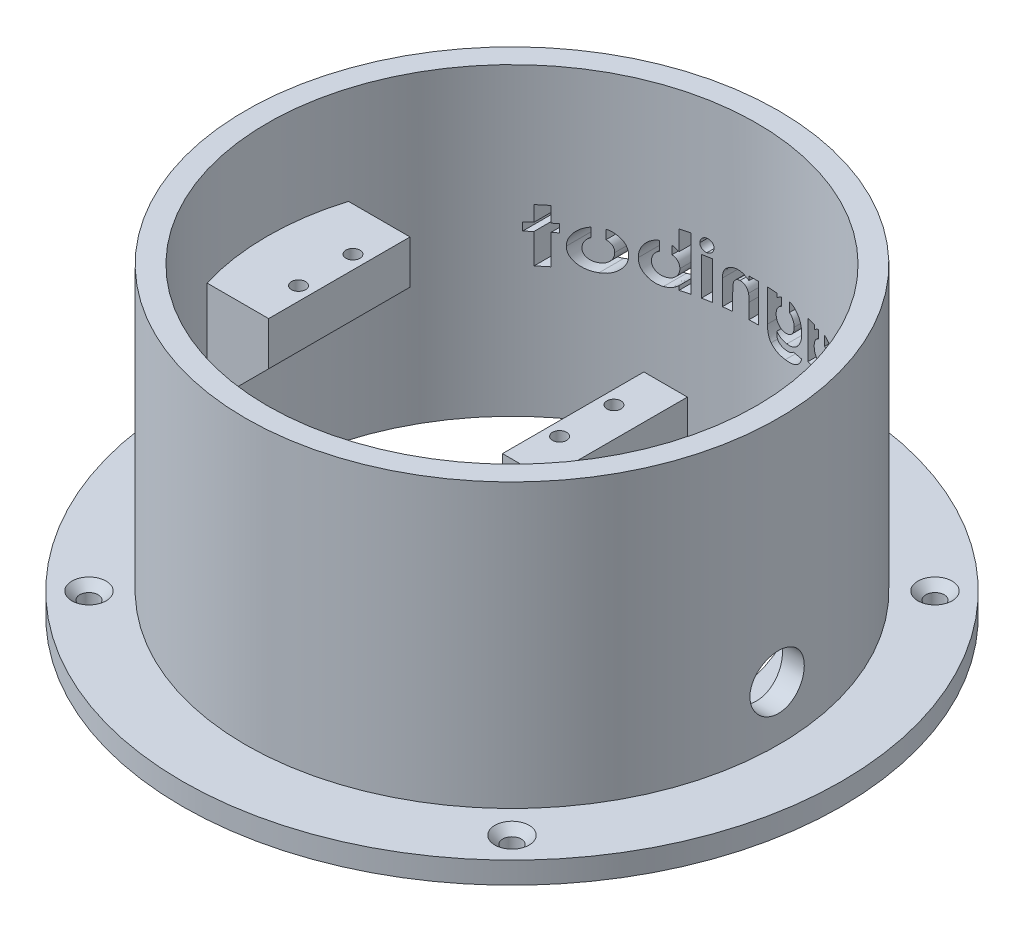
from build123d import *

# Parameters (mm, degrees)
SKETCH1_R                                           = 60.625
SKETCH1_R_2                                         = 45
BOSS_EXTRUDE1_DEPTH                                 = 4
SKETCH2_R                                           = 49
SKETCH2_R_2                                         = 45
BOSS_EXTRUDE2_DEPTH                                 = 52
SKETCH4_W                                           = 13.25
SKETCH4_H                                           = 8
SKETCH4_W_2                                         = 8
SKETCH4_H_2                                         = 38
BOSS_EXTRUDE4_DEPTH                                 = 13
BOSS_EXTRUDE5_DEPTH                                 = 4
SKETCH7_R                                           = 1.3
CUT_EXTRUDE4_DEPTH                                  = 7.2
SKETCH9_W                                           = 10
SKETCH9_H                                           = 24
CUT_EXTRUDE7_DEPTH                                  = 8
CUT_EXTRUDE8_REACH                                  = 111.625
SKETCH11_R                                          = 5
CUT_EXTRUDE9_DEPTH                                  = 5.0000001
CSK_FOR_M3_COUNTERSUNK_FLAT_HEAD_SCREW1_D           = 3.4
CSK_FOR_M3_COUNTERSUNK_FLAT_HEAD_SCREW1_DEPTH       = 4
CSK_FOR_M3_COUNTERSUNK_FLAT_HEAD_SCREW1_CSINK_D     = 6.3
CSK_FOR_M3_COUNTERSUNK_FLAT_HEAD_SCREW1_CSINK_ANGLE = 90
SKETCH18_W                                          = 1.709615384
SKETCH18_H                                          = 6.960576923
CUT_EXTRUDE10_DEPTH                                 = 45


with BuildPart() as part:
    # Sketch1 → Boss-Extrude1 (new body)
    with BuildSketch(Plane(origin=(0, 0, 0), x_dir=(1, 0, 0), z_dir=(0, 1, 0))):
        Circle(SKETCH1_R)
        Circle(SKETCH1_R_2, mode=Mode.SUBTRACT)
    extrude(amount=BOSS_EXTRUDE1_DEPTH)

    # Sketch2 → Boss-Extrude2 (add)
    with BuildSketch(Plane(origin=(0, 4, 0), x_dir=(1, 0, 0), z_dir=(0, 1, 0))):
        Circle(SKETCH2_R)
        Circle(SKETCH2_R_2, mode=Mode.SUBTRACT)
    extrude(amount=BOSS_EXTRUDE2_DEPTH)

    # Sketch4 → Boss-Extrude4 (add, symmetric)
    with BuildSketch(Plane.XY):
        with Locations((-38.375, 34)):
            Rectangle(SKETCH4_W, SKETCH4_H)
        Polygon((-31.75, 30), (-45, 30), (-45, 16.75), align=None)
        with Locations((15.25, 19)):
            Rectangle(SKETCH4_W_2, SKETCH4_H_2)
    extrude(amount=BOSS_EXTRUDE4_DEPTH, both=True)

    # Sketch5 → Boss-Extrude5 (add)
    with BuildSketch(Plane.XZ):
        with BuildLine():
            Line((11.25, 13), (29.067400866, 34.352382842))
            ThreePointArc((29.067400866, 34.352382842), (45, 0), (29.067400866, -34.352382842))
            Line((29.067400866, -34.352382842), (11.25, -13))
            Line((11.25, -13), (11.25, 13))
        make_face()
    extrude(amount=-BOSS_EXTRUDE5_DEPTH)

    # Sketch7 → Cut-Extrude4 (cut)
    with BuildSketch(Plane(origin=(0, 38, 0), x_dir=(1, 0, 0), z_dir=(0, 1, 0))):
        with Locations((-34.25, 5)):
            Circle(SKETCH7_R)
        with Locations((-34.25, -5)):
            Circle(SKETCH7_R)
        with Locations((13.75, 5)):
            Circle(SKETCH7_R)
        with Locations((13.75, -5)):
            Circle(SKETCH7_R)
    extrude(amount=-CUT_EXTRUDE4_DEPTH, mode=Mode.SUBTRACT)

    # Sketch9 → Cut-Extrude7 (cut)
    with BuildSketch(Plane.ZY.offset(-11.25)):
        with Locations((0, 17)):
            Rectangle(SKETCH9_W, SKETCH9_H)
    extrude(amount=-CUT_EXTRUDE7_DEPTH, mode=Mode.SUBTRACT)

    # Sketch11 → Cut-Extrude8 (cut, up to next)
    with BuildSketch(Plane(origin=(49, 0, 0), x_dir=(0, 0, -1), z_dir=(1, 0, 0)), mode=Mode.PRIVATE) as cut_extrude8_sk1:
        with Locations((0, 14)):
            Circle(SKETCH11_R)
    cut_extrude8_tool1 = extrude(cut_extrude8_sk1.sketch, amount=-CUT_EXTRUDE8_REACH, mode=Mode.PRIVATE) & part.part
    add(cut_extrude8_tool1.solids().sort_by_distance((49, 14, 0))[0], mode=Mode.SUBTRACT)

    # Sketch12 → Cut-Extrude9 (cut, through all)
    with BuildSketch(Plane(origin=(0, 4, 0), x_dir=(1, 0, 0), z_dir=(0, 1, 0))):
        with BuildLine():
            Line((29.479537487, 22.359715328), (27.25, 19.687836398))
            Line((27.25, 19.687836398), (27.25, -19.687836398))
            Line((27.25, -19.687836398), (29.479537487, -22.359715328))
            ThreePointArc((29.479537487, -22.359715328), (37, 0), (29.479537487, 22.359715328))
        make_face()
        Polygon((27.25, -19.687836398), (27.25, 19.687836398), (24.25, 16.092634774), (24.25, -16.092634774), align=None)
    extrude(amount=-CUT_EXTRUDE9_DEPTH, mode=Mode.SUBTRACT)

    # CSK for M3 Countersunk Flat Head Screw1
    with Locations(Plane(origin=(0, 4, 0), x_dir=(1, 0, 0), z_dir=(0, 1, 0))):
        with Locations((-38.890872965, 38.890872965), (-38.890872965, -38.890872965), (38.890872965, -38.890872965), (38.890872965, 38.890872965)):
            CounterSinkHole(CSK_FOR_M3_COUNTERSUNK_FLAT_HEAD_SCREW1_D / 2, CSK_FOR_M3_COUNTERSUNK_FLAT_HEAD_SCREW1_CSINK_D / 2, depth=CSK_FOR_M3_COUNTERSUNK_FLAT_HEAD_SCREW1_DEPTH, counter_sink_angle=CSK_FOR_M3_COUNTERSUNK_FLAT_HEAD_SCREW1_CSINK_ANGLE)

    # Sketch18 → Cut-Extrude10 (cut)
    with BuildSketch(Plane(origin=(0, 0, -13), x_dir=(-1, 0, 0), z_dir=(0, 0, -1))):
        with BuildLine():
            add(Edge.make_bspline(
                [(-26.842487981, 29.495192308), (-26.988196434, 29.498038901), (-27.204965825, 29.462307141), (-27.475994694, 29.354907901), (-27.664862129, 29.241566866), (-27.836779719, 29.100355471), (-27.987937046, 28.932127623), (-28.113371328, 28.737009869), (-28.201046352, 28.555679373), (-28.254794589, 28.392139668), (-28.294305339, 28.251942188), (-28.323177251, 28.094008869), (-28.347279044, 27.920113495), (-28.369621116, 27.730048993), (-28.385267336, 27.442939995), (-28.394826017, 27.219060717), (-28.391826923, 27.064332933)],
                knots=[0, 0, 0, 0, 0.13355216, 0.199704678, 0.267120188, 0.335277742, 0.403628311, 0.474205446, 0.54799425, 0.588135642, 0.632411552, 0.681857329, 0.73562936, 0.793897036, 0.857789304, 1, 1, 1, 1], degree=3))
            Line((-28.391826923, 27.064332933), (-28.391826923, 24))
            Line((-28.391826923, 24), (-30.101442308, 24))
            Line((-30.101442308, 24), (-30.101442308, 30.960576923))
            Line((-30.101442308, 30.960576923), (-28.391826923, 30.960576923))
            Line((-28.391826923, 30.960576923), (-28.391826923, 30.128665865))
            add(Edge.make_bspline(
                [(-28.391826923, 30.128665865), (-28.246518571, 30.28386113), (-28.00929586, 30.492748527), (-27.659062917, 30.716852491), (-27.38650362, 30.85144348), (-27.10067853, 30.954023668), (-26.698562474, 31.056158967), (-26.384211282, 31.08134908), (-26.172761418, 31.082692308)],
                knots=[0, 0, 0, 0, 0.256335531, 0.379114138, 0.500550811, 0.622115809, 0.744714581, 1, 1, 1, 1], degree=3))
            add(Edge.make_bspline(
                [(-26.172761418, 31.082692308), (-25.960830072, 31.083493322), (-25.645660174, 31.046822542), (-25.250117073, 30.912238992), (-24.976393607, 30.770998946), (-24.72038138, 30.596258979), (-24.411202082, 30.302229143), (-24.225552609, 30.035457192), (-24.12351262, 29.842457933)],
                knots=[0, 0, 0, 0, 0.251955439, 0.373413672, 0.494801292, 0.617068654, 0.7406196, 1, 1, 1, 1], degree=3))
            add(Edge.make_bspline(
                [(-24.12351262, 29.842457933), (-23.98885255, 30.038239174), (-23.754904191, 30.305456134), (-23.388343741, 30.596264158), (-23.091852347, 30.772294093), (-22.777453929, 30.911749639), (-22.333011237, 31.046004506), (-21.983922354, 31.083556782), (-21.749894832, 31.082692308)],
                knots=[0, 0, 0, 0, 0.25544547, 0.37917652, 0.501904822, 0.625344245, 0.74827832, 1, 1, 1, 1], degree=3))
            add(Edge.make_bspline(
                [(-21.749894832, 31.082692308), (-21.511457683, 31.084814494), (-21.160136901, 31.042896333), (-20.719737815, 30.899120432), (-20.425124803, 30.746464528), (-20.158725744, 30.565394097), (-19.931721755, 30.351514057), (-19.743329163, 30.112219798), (-19.620661389, 29.888780681), (-19.541360075, 29.691234213), (-19.493476883, 29.519331883), (-19.448692906, 29.327381136), (-19.416513393, 29.112802035), (-19.386505118, 28.877610967), (-19.362172784, 28.520569263), (-19.354973526, 28.241721525), (-19.355288462, 28.048888221)],
                knots=[0, 0, 0, 0, 0.16090351, 0.236985873, 0.311729383, 0.384306569, 0.453908175, 0.521546124, 0.589231814, 0.625292706, 0.665128129, 0.709631799, 0.75836798, 0.811604142, 0.869763281, 1, 1, 1, 1], degree=3))
            Line((-19.355288462, 28.048888221), (-19.355288462, 24))
            Line((-19.355288462, 24), (-21.064903846, 24))
            Line((-21.064903846, 24), (-21.064903846, 27.495552885))
            add(Edge.make_bspline(
                [(-21.064903846, 27.495552885), (-21.068140687, 27.674833554), (-21.070356959, 27.932935713), (-21.106654363, 28.25937097), (-21.137126743, 28.470145996), (-21.18072093, 28.657138802), (-21.233878599, 28.820796093), (-21.295540637, 28.961354328), (-21.369995815, 29.078798806), (-21.453385673, 29.177705228), (-21.546144876, 29.262489002), (-21.647306212, 29.334821229), (-21.757787048, 29.396493405), (-21.880480962, 29.438131039), (-22.059414371, 29.483235592), (-22.200832369, 29.497359509), (-22.29750601, 29.495192308)],
                knots=[0, 0, 0, 0, 0.200235118, 0.287286636, 0.36626042, 0.437682721, 0.501179832, 0.55802122, 0.608412149, 0.655743055, 0.701943669, 0.748215056, 0.794251934, 0.84250453, 0.892236791, 1, 1, 1, 1], degree=3))
            add(Edge.make_bspline(
                [(-22.29750601, 29.495192308), (-22.447521501, 29.496164897), (-22.671943821, 29.466348726), (-22.949430786, 29.356428903), (-23.141804083, 29.246128469), (-23.316353958, 29.108174057), (-23.469039265, 28.944596141), (-23.595136439, 28.754397482), (-23.682423957, 28.577934251), (-23.736967516, 28.418375354), (-23.775443704, 28.281726094), (-23.805431502, 28.127195878), (-23.828915596, 27.95635021), (-23.851390901, 27.768221413), (-23.866979995, 27.483641738), (-23.8765728, 27.261678322), (-23.873557692, 27.108218149)],
                knots=[0, 0, 0, 0, 0.138576891, 0.20607346, 0.274463188, 0.342600369, 0.410740079, 0.480118385, 0.552600476, 0.591784346, 0.635663039, 0.683568788, 0.736964635, 0.79487093, 0.858420857, 1, 1, 1, 1], degree=3))
            Line((-23.873557692, 27.108218149), (-23.873557692, 24))
            Line((-23.873557692, 24), (-25.583173077, 24))
            Line((-25.583173077, 24), (-25.583173077, 27.337184495))
            add(Edge.make_bspline(
                [(-25.583173077, 27.337184495), (-25.581929367, 27.480364046), (-25.587494863, 27.687209995), (-25.602902154, 27.952402752), (-25.6182858, 28.127983872), (-25.636060725, 28.288035163), (-25.661704733, 28.431681339), (-25.68864776, 28.559713845), (-25.734841386, 28.70515501), (-25.799934185, 28.866327836), (-25.897184162, 29.037243969), (-26.014771218, 29.180341574), (-26.149729591, 29.29675473), (-26.302220032, 29.385397216), (-26.529198096, 29.475712011), (-26.717247278, 29.492268234), (-26.842487981, 29.495192308)],
                knots=[0, 0, 0, 0, 0.151067163, 0.218305464, 0.280286667, 0.337063553, 0.388152346, 0.434234333, 0.474994116, 0.549030637, 0.617296196, 0.681662637, 0.743542005, 0.804319575, 0.867012585, 1, 1, 1, 1], degree=3))
        make_face()
        with BuildLine():
            Line((-10.685096154, 30.960576923), (-12.394711538, 30.960576923))
            Line((-12.394711538, 30.960576923), (-12.394711538, 30.176367188))
            add(Edge.make_bspline(
                [(-13.394766241, 30.846325903), (-13.310273388, 30.811242607), (-13.135129326, 30.729510449), (-12.789159208, 30.520493059), (-12.5451071, 30.323924112), (-12.394711538, 30.176367188)],
                knots=[0.505665216, 0.505665216, 0.505665216, 0.505665216, 0.617680221, 0.742091207, 1, 1, 1, 1], degree=3))
            Line((-13.394766241, 30.846325903), (-13.394766241, 29.329440504))
            add(Edge.make_bspline(
                [(-12.272596154, 27.49936899), (-12.275060695, 27.640851441), (-12.286903949, 27.850610329), (-12.347552937, 28.118783015), (-12.407830208, 28.305751844), (-12.486754381, 28.48203362), (-12.585417382, 28.645666236), (-12.69736389, 28.802320919), (-12.829721006, 28.943228332), (-12.971811749, 29.07413986), (-13.126905871, 29.186060901), (-13.268832014, 29.269936251), (-13.359799297, 29.313990727), (-13.394766241, 29.329440504)],
                knots=[0, 0, 0, 0, 0.135095843, 0.199062931, 0.26154836, 0.322044302, 0.382646423, 0.443384787, 0.505154721, 0.566515904, 0.627254268, 0.687026267, 0.723436876, 0.723436876, 0.723436876, 0.723436876], degree=3))
            add(Edge.make_bspline(
                [(-14.235982572, 25.465384615), (-14.10011477, 25.467643209), (-13.898799708, 25.480332454), (-13.640806303, 25.53963291), (-13.460804722, 25.604109848), (-13.288221764, 25.681696153), (-13.124620215, 25.777647683), (-12.971773985, 25.89305892), (-12.828909303, 26.024925234), (-12.698001522, 26.169745041), (-12.58481344, 26.328550432), (-12.486224946, 26.496261974), (-12.408680476, 26.676846784), (-12.347134367, 26.867138563), (-12.286934546, 27.140607111), (-12.275196888, 27.354702397), (-12.272596154, 27.49936899)],
                knots=[0, 0, 0, 0, 0.128661741, 0.189789734, 0.249707447, 0.309188905, 0.368499841, 0.428643518, 0.489936978, 0.552121002, 0.612878024, 0.674050383, 0.735729182, 0.798304624, 0.862952782, 1, 1, 1, 1], degree=3))
            add(Edge.make_bspline(
                [(-16.180288462, 27.493644832), (-16.177753543, 27.352107797), (-16.165553709, 27.142550903), (-16.105972787, 26.873813056), (-16.042025644, 26.686589642), (-15.963884487, 26.507939562), (-15.868781379, 26.338693239), (-15.75196058, 26.181841637), (-15.622339039, 26.033673393), (-15.477365155, 25.901365306), (-15.324904215, 25.783886331), (-15.162873633, 25.685597292), (-14.993031423, 25.606139103), (-14.815948987, 25.541463433), (-14.564127631, 25.483260542), (-14.368366115, 25.465966115), (-14.235982572, 25.465384615)],
                knots=[0, 0, 0, 0, 0.135364742, 0.199460916, 0.262263612, 0.323991109, 0.385461119, 0.447170687, 0.510418175, 0.573170928, 0.634270788, 0.693953647, 0.753722967, 0.813083582, 0.873628543, 1, 1, 1, 1], degree=3))
            add(Edge.make_bspline(
                [(-15.104766241, 29.310891047), (-15.128357367, 29.299714144), (-15.207610898, 29.260034442), (-15.337370386, 29.180793558), (-15.488973559, 29.065116813), (-15.631033087, 28.934431912), (-15.760541149, 28.790785074), (-15.872185186, 28.634035169), (-15.967062601, 28.468406347), (-16.047311646, 28.293397945), (-16.10472424, 28.106949337), (-16.166516957, 27.841905768), (-16.177251536, 27.633746436), (-16.180288462, 27.493644832)],
                knots=[0.284645674, 0.284645674, 0.284645674, 0.284645674, 0.30974405, 0.369855539, 0.430536995, 0.492876096, 0.555257199, 0.616197084, 0.67757746, 0.738630831, 0.800921896, 0.864881541, 1, 1, 1, 1], degree=3))
            Line((-15.104766241, 29.310891047), (-15.104766241, 31.04733117))
            add(Edge.make_bspline(
                [(-17.889903846, 27.466932091), (-17.887893117, 27.720081558), (-17.86504439, 28.095154051), (-17.760403741, 28.575169229), (-17.655770658, 28.910764723), (-17.521064587, 29.22848271), (-17.357029895, 29.5288338), (-17.161404408, 29.811035446), (-16.935982638, 30.070283963), (-16.692582034, 30.307896996), (-16.432186421, 30.514760791), (-16.158868224, 30.690491148), (-15.872334992, 30.833991927), (-15.57263517, 30.944747788), (-15.315122826, 31.012054464), (-15.157587593, 31.039528345), (-15.104766241, 31.04733117)],
                knots=[0, 0, 0, 0, 0.139308968, 0.205473642, 0.26959838, 0.332253223, 0.394830003, 0.45737553, 0.520581844, 0.583374035, 0.644082429, 0.703039519, 0.761664045, 0.819843943, 0.878346403, 0.907680046, 0.907680046, 0.907680046, 0.907680046], degree=3))
            add(Edge.make_bspline(
                [(-14.550811298, 23.877884615), (-14.771194945, 23.875519618), (-15.097918989, 23.909256248), (-15.518197746, 24.017521116), (-15.819029415, 24.13040656), (-16.107936569, 24.27691408), (-16.387131536, 24.452984729), (-16.651827659, 24.664864734), (-16.904228747, 24.903368832), (-17.135325055, 25.165726181), (-17.337353842, 25.448294059), (-17.507641007, 25.747064711), (-17.647178129, 26.061049428), (-17.756829985, 26.390010448), (-17.863179509, 26.856878675), (-17.889066519, 27.221178873), (-17.889903846, 27.466932091)],
                knots=[0, 0, 0, 0, 0.121092325, 0.179634237, 0.238303512, 0.297437091, 0.357506849, 0.419513154, 0.483600041, 0.548295031, 0.611486872, 0.674312645, 0.737107248, 0.800159515, 0.864737133, 1, 1, 1, 1], degree=3))
            add(Edge.make_bspline(
                [(-12.394711538, 24.759405048), (-12.556438107, 24.613336017), (-12.80579393, 24.412909112), (-13.162727189, 24.202367243), (-13.424496711, 24.08000868), (-13.692348157, 23.989796988), (-14.064934751, 23.90107922), (-14.355434994, 23.879194523), (-14.550811298, 23.877884615)],
                knots=[0, 0, 0, 0, 0.273943506, 0.399987178, 0.519718967, 0.636176176, 0.754371141, 1, 1, 1, 1], degree=3))
            Line((-12.394711538, 24.759405048), (-12.394711538, 24))
            Line((-12.394711538, 24), (-10.685096154, 24))
            Line((-10.685096154, 24), (-10.685096154, 30.960576923))
        make_face()
        with BuildLine():
            Line((-2.014903846, 30.960576923), (-3.846634615, 30.960576923))
            Line((-3.846634615, 30.960576923), (-3.846634615, 30.185907452))
            add(Edge.make_bspline(
                [(-4.767307692, 30.814230123), (-4.724477087, 30.794772406), (-4.590493141, 30.729827243), (-4.269492644, 30.538805478), (-4.012351526, 30.336800768), (-3.846634615, 30.185907452)],
                knots=[0.536763775, 0.536763775, 0.536763775, 0.536763775, 0.595177246, 0.721609329, 1, 1, 1, 1], degree=3))
            Line((-4.767307692, 30.814230123), (-4.767307692, 29.320900687))
            add(Edge.make_bspline(
                [(-3.724519231, 27.547070313), (-3.723985612, 27.684921804), (-3.738077468, 27.888553288), (-3.795878184, 28.149010676), (-3.852746707, 28.331467089), (-3.92694536, 28.503911256), (-4.019968331, 28.66473411), (-4.126349389, 28.81690634), (-4.251607924, 28.955244463), (-4.386618444, 29.083193729), (-4.535464026, 29.191438066), (-4.662702685, 29.26982308), (-4.741830963, 29.309083747), (-4.767307692, 29.320900687)],
                knots=[0, 0, 0, 0, 0.135592213, 0.199608616, 0.261894986, 0.32322003, 0.383707537, 0.444249949, 0.505361089, 0.566851635, 0.626748183, 0.685935715, 0.713527333, 0.713527333, 0.713527333, 0.713527333], degree=3))
            add(Edge.make_bspline(
                [(-5.584870793, 25.5875), (-5.454885958, 25.585020274), (-5.263798901, 25.604031441), (-5.018163858, 25.660529884), (-4.845887876, 25.719523311), (-4.683344123, 25.796656464), (-4.528349074, 25.888670415), (-4.38419113, 26.000026641), (-4.248136037, 26.125920215), (-4.125355319, 26.26591114), (-4.016979898, 26.417589382), (-3.927957635, 26.580982169), (-3.852112777, 26.753503944), (-3.796017699, 26.93758312), (-3.737790866, 27.201095495), (-3.724286438, 27.407370932), (-3.724519231, 27.547070313)],
                knots=[0, 0, 0, 0, 0.128347402, 0.189067593, 0.248938142, 0.308023861, 0.366703119, 0.426834097, 0.487804601, 0.549753476, 0.610659063, 0.671749482, 0.733442395, 0.796702453, 0.861717283, 1, 1, 1, 1], degree=3))
            add(Edge.make_bspline(
                [(-7.510096154, 27.560426683), (-7.512631606, 27.421551138), (-7.493433253, 27.218005211), (-7.437602911, 26.955335594), (-7.376070293, 26.772902995), (-7.298907685, 26.599118093), (-7.206250188, 26.434062959), (-7.09186074, 26.281684873), (-6.964837373, 26.138630134), (-6.824314641, 26.009292499), (-6.67305439, 25.896795809), (-6.514171146, 25.799646023), (-6.344228396, 25.723890246), (-6.166910774, 25.66253924), (-5.914630439, 25.602081397), (-5.71748417, 25.59010512), (-5.584870793, 25.5875)],
                knots=[0, 0, 0, 0, 0.134674643, 0.197931502, 0.260447922, 0.321293636, 0.382442821, 0.443853595, 0.505984202, 0.568071793, 0.628986467, 0.688848821, 0.748567548, 0.80932852, 0.870916168, 1, 1, 1, 1], degree=3))
            add(Edge.make_bspline(
                [(-6.477307692, 29.308506905), (-6.496110819, 29.299218872), (-6.569021818, 29.261444461), (-6.691391764, 29.186398323), (-6.840503272, 29.074852735), (-6.977284603, 28.945757425), (-7.10407087, 28.806266755), (-7.210527495, 28.652749523), (-7.305390111, 28.493946497), (-7.379193317, 28.323470163), (-7.440093553, 28.14593706), (-7.491184894, 27.890883778), (-7.513785795, 27.694490093), (-7.510096154, 27.560426683)],
                knots=[0.292846116, 0.292846116, 0.292846116, 0.292846116, 0.313596585, 0.374077456, 0.434784119, 0.497609537, 0.5600519, 0.621032311, 0.682272297, 0.742887436, 0.804620819, 0.867735932, 1, 1, 1, 1], degree=3))
            Line((-6.477307692, 29.308506905), (-6.477307692, 31.053484371))
            add(Edge.make_bspline(
                [(-8.210351562, 30.182091346), (-8.062892974, 30.32841237), (-7.824605249, 30.524618663), (-7.477383775, 30.735792746), (-7.208361065, 30.861886627), (-6.928782705, 30.96208958), (-6.683039299, 31.021567874), (-6.531127889, 31.046194335), (-6.477307692, 31.053484371)],
                knots=[0, 0, 0, 0, 0.256681043, 0.3797841, 0.501470579, 0.623319496, 0.746312038, 0.8134232, 0.8134232, 0.8134232, 0.8134232], degree=3))
            add(Edge.make_bspline(
                [(-9.219711538, 27.541346154), (-9.221119919, 27.802624039), (-9.190880522, 28.187260302), (-9.085236081, 28.680667949), (-8.975256648, 29.02328411), (-8.830419755, 29.344336616), (-8.597264234, 29.747009659), (-8.376926533, 30.019294713), (-8.210351562, 30.182091346)],
                knots=[0, 0, 0, 0, 0.269734209, 0.396745187, 0.520318914, 0.64054729, 0.759723539, 1, 1, 1, 1], degree=3))
            add(Edge.make_bspline(
                [(-5.930228365, 24), (-6.152932763, 23.998495138), (-6.483421931, 24.029911389), (-6.90743633, 24.135684656), (-7.208893191, 24.243870114), (-7.494840772, 24.387709988), (-7.769346837, 24.558788475), (-8.027324309, 24.766145612), (-8.272332389, 24.998190748), (-8.493775749, 25.256120065), (-8.688634356, 25.533135598), (-8.852897135, 25.827326537), (-8.986509958, 26.13842036), (-9.092853484, 26.465107174), (-9.192743563, 26.93200642), (-9.218830866, 27.295560831), (-9.219711538, 27.541346154)],
                knots=[0, 0, 0, 0, 0.123700343, 0.183445285, 0.242476179, 0.301272795, 0.36098846, 0.421869333, 0.484863659, 0.548268086, 0.61043108, 0.672769643, 0.735140257, 0.798288065, 0.863379995, 1, 1, 1, 1], degree=3))
            add(Edge.make_bspline(
                [(-3.846634615, 24.868164063), (-3.98909843, 24.721521045), (-4.215491951, 24.523655782), (-4.547876247, 24.317476268), (-4.797702087, 24.197316109), (-5.059589779, 24.109448793), (-5.435024982, 24.022930448), (-5.72974928, 24.001013175), (-5.930228365, 24)],
                knots=[0, 0, 0, 0, 0.263927751, 0.385523834, 0.50370538, 0.620733321, 0.741155395, 1, 1, 1, 1], degree=3))
            add(Edge.make_bspline(
                [(-5.735606971, 22.900961538), (-5.525196523, 22.899276388), (-5.22448664, 22.923597434), (-4.851215663, 23.01425836), (-4.620987063, 23.11085449), (-4.422356529, 23.226997653), (-4.256650546, 23.361885863), (-4.119825558, 23.510466811), (-4.030327646, 23.650243846), (-3.977144805, 23.77704456), (-3.940929942, 23.886535102), (-3.913430242, 24.012742877), (-3.888388037, 24.153305504), (-3.869711495, 24.310034838), (-3.852264706, 24.549844117), (-3.844166728, 24.73762836), (-3.846634615, 24.868164063)],
                knots=[0, 0, 0, 0, 0.19772075, 0.282265633, 0.359994231, 0.431569103, 0.497870001, 0.560090238, 0.620807047, 0.652681998, 0.689174246, 0.729059971, 0.773983044, 0.823375087, 0.877349713, 1, 1, 1, 1], degree=3))
            add(Edge.make_bspline(
                [(-7.326923077, 23.511538462), (-7.242380589, 23.410960965), (-7.09438231, 23.276179867), (-6.865258268, 23.136766102), (-6.674394322, 23.050135373), (-6.464624278, 22.984387324), (-6.152217667, 22.915381349), (-5.904480947, 22.901982511), (-5.735606971, 22.900961538)],
                knots=[0, 0, 0, 0, 0.22365493, 0.337943226, 0.455777244, 0.579824406, 0.711809474, 1, 1, 1, 1], degree=3))
            Line((-7.326923077, 23.511538462), (-9.22734375, 23.511538462))
            add(Edge.make_bspline(
                [(-5.607767428, 21.313461538), (-5.923289422, 21.313265407), (-6.380155639, 21.337583659), (-6.955064069, 21.447487367), (-7.329970807, 21.55820764), (-7.669881143, 21.701190442), (-7.981201857, 21.872605913), (-8.263321238, 22.077558287), (-8.520560809, 22.307942318), (-8.746742268, 22.568885243), (-9.008284666, 22.958824451), (-9.152772399, 23.284583153), (-9.22734375, 23.511538462)],
                knots=[0, 0, 0, 0, 0.207410699, 0.299345031, 0.383942479, 0.463709986, 0.54113669, 0.616854835, 0.692286579, 0.767513249, 0.843065229, 1, 1, 1, 1], degree=3))
            add(Edge.make_bspline(
                [(-2.726607572, 22.435396635), (-2.883402534, 22.249158648), (-3.157412194, 22.001321583), (-3.579225271, 21.744105205), (-3.926838228, 21.584854194), (-4.305110793, 21.463833728), (-4.864867171, 21.343405218), (-5.305869432, 21.312752008), (-5.607767428, 21.313461538)],
                knots=[0, 0, 0, 0, 0.228421157, 0.343996608, 0.46295648, 0.586702957, 0.716302913, 1, 1, 1, 1], degree=3))
            add(Edge.make_bspline(
                [(-2.014903846, 25.022716346), (-2.01605019, 24.748857441), (-2.032888638, 24.350205066), (-2.10790658, 23.841573981), (-2.185622487, 23.501846955), (-2.286280671, 23.191966583), (-2.445487195, 22.825495506), (-2.603406818, 22.579293056), (-2.726607572, 22.435396635)],
                knots=[0, 0, 0, 0, 0.300233823, 0.436256712, 0.562884572, 0.681680621, 0.792783658, 1, 1, 1, 1], degree=3))
            Line((-2.014903846, 25.022716346), (-2.014903846, 30.960576923))
        make_face()
        with BuildLine():
            add(Edge.make_bspline(
                [(1.484465144, 28.171003606), (1.466486465, 28.102133912), (1.453307231, 27.985137756), (1.43216254, 27.814589763), (1.425478116, 27.651348174), (1.414090003, 27.46451461), (1.408057747, 27.168010661), (1.404442551, 26.933984684), (1.404326923, 26.770492788)],
                knots=[0, 0, 0, 0, 0.151475868, 0.251213212, 0.366854146, 0.500124386, 0.650932297, 1, 1, 1, 1], degree=3))
            Line((1.404326923, 26.770492788), (1.404326923, 24))
            Line((1.404326923, 24), (-0.305288462, 24))
            Line((-0.305288462, 24), (-0.305288462, 30.960576923))
            Line((-0.305288462, 30.960576923), (1.404326923, 30.960576923))
            Line((1.404326923, 30.960576923), (1.404326923, 30.22406851))
            add(Edge.make_bspline(
                [(1.404326923, 30.22406851), (1.588082988, 30.372253646), (1.863824612, 30.569162852), (2.239123782, 30.781038124), (2.496605832, 30.89620558), (2.749040746, 30.978882544), (3.08353522, 31.058574307), (3.339932733, 31.083729401), (3.510817308, 31.082692308)],
                knots=[0, 0, 0, 0, 0.30498931, 0.436681429, 0.556242249, 0.668759084, 0.77937854, 1, 1, 1, 1], degree=3))
            add(Edge.make_bspline(
                [(3.510817308, 31.082692308), (3.680448828, 31.08075736), (3.933391103, 31.064483298), (4.256758659, 30.985147067), (4.487401972, 30.907574271), (4.707179343, 30.805055755), (4.99224116, 30.641514609), (5.182040003, 30.47978274), (5.302478966, 30.365264423)],
                knots=[0, 0, 0, 0, 0.257369373, 0.381171348, 0.503298819, 0.625247689, 0.747811067, 1, 1, 1, 1], degree=3))
            add(Edge.make_bspline(
                [(5.302478966, 30.365264423), (5.405932581, 30.262683941), (5.5432377, 30.088552258), (5.685323238, 29.826244326), (5.773727429, 29.609531908), (5.83891886, 29.372851877), (5.908035146, 29.024814881), (5.921535144, 28.750707555), (5.922596154, 28.5640625)],
                knots=[0, 0, 0, 0, 0.223210024, 0.337545587, 0.456528166, 0.581243817, 0.713405156, 1, 1, 1, 1], degree=3))
            Line((5.922596154, 28.5640625), (5.922596154, 24))
            Line((5.922596154, 24), (4.212980769, 24))
            Line((4.212980769, 24), (4.212980769, 27.022355769))
            add(Edge.make_bspline(
                [(4.212980769, 27.022355769), (4.212493766, 27.211243199), (4.210812206, 27.481734912), (4.1962179, 27.824407045), (4.18675366, 28.042839559), (4.168165199, 28.234750825), (4.151402553, 28.401355154), (4.125681655, 28.541141203), (4.092214633, 28.691502171), (4.033772991, 28.852490497), (3.943045042, 29.022120722), (3.827944434, 29.166217201), (3.693170097, 29.285829147), (3.538879239, 29.38034416), (3.303028662, 29.472102945), (3.109660441, 29.495738343), (2.978470553, 29.495192308)],
                knots=[0, 0, 0, 0, 0.179518406, 0.256936513, 0.325929829, 0.387212867, 0.440139084, 0.484952067, 0.522188202, 0.586422033, 0.647003712, 0.704201966, 0.760716033, 0.817414001, 0.87521257, 1, 1, 1, 1], degree=3))
            add(Edge.make_bspline(
                [(2.978470553, 29.495192308), (2.805477806, 29.493406973), (2.544941693, 29.455299423), (2.233950501, 29.302362646), (2.025539256, 29.146180395), (1.84161366, 28.953101705), (1.632730493, 28.637036758), (1.530975425, 28.363566523), (1.484465144, 28.171003606)],
                knots=[0, 0, 0, 0, 0.240657962, 0.35738999, 0.477137096, 0.600008858, 0.725224946, 1, 1, 1, 1], degree=3))
        make_face()
        with Locations((8.364903846, 27.480288462)):
            Rectangle(SKETCH18_W, SKETCH18_H)
        with BuildLine():
            add(Edge.make_bspline(
                [(7.265865385, 32.750330529), (7.26826571, 32.898800121), (7.301809284, 33.123992504), (7.442819571, 33.387441681), (7.581566689, 33.56215972), (7.748301082, 33.708202376), (8.002527482, 33.849907978), (8.217416018, 33.892511937), (8.36108774, 33.891346154)],
                knots=[0, 0, 0, 0, 0.255026588, 0.378937478, 0.506522648, 0.634371171, 0.754975888, 1, 1, 1, 1], degree=3))
            add(Edge.make_bspline(
                [(8.36108774, 33.891346154), (8.50572535, 33.893726285), (8.722578746, 33.848887063), (8.976980236, 33.702667204), (9.145189704, 33.553861868), (9.284954848, 33.37588626), (9.429451762, 33.107458896), (9.461110928, 32.876834089), (9.463942308, 32.725525841)],
                knots=[0, 0, 0, 0, 0.242962799, 0.363854564, 0.490606197, 0.618739544, 0.743300131, 1, 1, 1, 1], degree=3))
            add(Edge.make_bspline(
                [(9.463942308, 32.725525841), (9.462823205, 32.575352936), (9.426744781, 32.34888392), (9.287851515, 32.08058497), (9.146978933, 31.905250348), (8.980599716, 31.758807889), (8.731970407, 31.610310399), (8.516181568, 31.571234077), (8.374444111, 31.571153846)],
                knots=[0, 0, 0, 0, 0.256468948, 0.381954886, 0.51070434, 0.637377053, 0.757775202, 1, 1, 1, 1], degree=3))
            add(Edge.make_bspline(
                [(8.374444111, 31.571153846), (8.228392073, 31.568584808), (8.010279618, 31.613961149), (7.752417461, 31.759104087), (7.584921087, 31.910946082), (7.44360454, 32.090205686), (7.304907407, 32.365264446), (7.265535894, 32.595858978), (7.265865385, 32.750330529)],
                knots=[0, 0, 0, 0, 0.242758603, 0.363442651, 0.489711254, 0.617482185, 0.742279995, 1, 1, 1, 1], degree=3))
        make_face()
        with BuildLine():
            Line((12.516826923, 30.149654447), (12.516826923, 33.769230769))
            Line((12.516826923, 33.769230769), (10.807211538, 33.769230769))
            Line((10.807211538, 33.769230769), (10.807211538, 24))
            Line((10.807211538, 24), (12.516826923, 24))
            Line((12.516826923, 24), (12.516826923, 24.759405048))
            add(Edge.make_bspline(
                [(14.676742788, 23.877884615), (14.481340525, 23.879044105), (14.190295273, 23.90141522), (13.816420162, 23.989838815), (13.547100901, 24.079591834), (13.284859025, 24.202413115), (12.927897083, 24.412875007), (12.678560162, 24.613354615), (12.516826923, 24.759405048)],
                knots=[0, 0, 0, 0, 0.245252626, 0.364042958, 0.481077093, 0.600625487, 0.726476096, 1, 1, 1, 1], degree=3))
            add(Edge.make_bspline(
                [(18.012019231, 27.466932091), (18.011181865, 27.221178923), (17.985294968, 26.856878579), (17.878945263, 26.390010584), (17.7692939, 26.061048931), (17.629754954, 25.747066559), (17.459474608, 25.448287137), (17.257420023, 25.165752444), (17.026422023, 24.903268641), (16.774022458, 24.665571143), (16.511040433, 24.452305205), (16.232237726, 24.277564662), (15.944584836, 24.129931236), (15.643546412, 24.017226421), (15.22306157, 23.909995441), (14.896589543, 23.874990677), (14.676742788, 23.877884615)],
                knots=[0, 0, 0, 0, 0.135343154, 0.199959102, 0.263048795, 0.32588067, 0.388743734, 0.451973083, 0.516706474, 0.580831401, 0.642600426, 0.702705839, 0.761562083, 0.820266181, 0.879181718, 1, 1, 1, 1], degree=3))
            add(Edge.make_bspline(
                [(15.218097957, 31.048901427), (15.274501403, 31.040721291), (15.436248135, 31.01276704), (15.697481837, 30.94541187), (15.996490365, 30.834072506), (16.281554263, 30.6893286), (16.555871945, 30.516072705), (16.814713657, 30.307102437), (17.058205037, 30.070412022), (17.283440222, 29.810980855), (17.479354913, 29.528924179), (17.642538467, 29.22795498), (17.780866368, 28.91162813), (17.881742065, 28.574710049), (17.987743146, 28.095349683), (18.009700374, 27.719978228), (18.012019231, 27.466932091)],
                knots=[0.090050164, 0.090050164, 0.090050164, 0.090050164, 0.121379711, 0.180255513, 0.238142193, 0.296488846, 0.355775695, 0.416246569, 0.479075999, 0.542319797, 0.604902417, 0.667516308, 0.730345738, 0.794404503, 0.860608415, 1, 1, 1, 1], degree=3))
            Line((15.218097957, 31.048901427), (15.218097957, 29.314704791))
            add(Edge.make_bspline(
                [(16.302403846, 27.493644832), (16.299366921, 27.633746438), (16.28863234, 27.841905764), (16.226839627, 28.106949342), (16.169427021, 28.293397925), (16.089178022, 28.468406422), (15.994300434, 28.634034891), (15.882657044, 28.790786113), (15.753146514, 28.934427931), (15.611096154, 29.06513148), (15.459459761, 29.180740652), (15.327073536, 29.261851626), (15.244691035, 29.302412618), (15.218097957, 29.314704791)],
                knots=[0, 0, 0, 0, 0.134801712, 0.198611423, 0.260756464, 0.321666712, 0.3829032, 0.443700229, 0.505935097, 0.568128061, 0.628667267, 0.688637842, 0.716736573, 0.716736573, 0.716736573, 0.716736573], degree=3))
            add(Edge.make_bspline(
                [(14.358097957, 25.465384615), (14.490373882, 25.46633226), (14.68583074, 25.482503424), (14.937152433, 25.542290355), (15.11434859, 25.60505308), (15.283662909, 25.686858719), (15.44663417, 25.782563199), (15.597636669, 25.902145009), (15.742594365, 26.0335741), (15.872292584, 26.181788724), (15.988648215, 26.339247216), (16.086387681, 26.507354655), (16.16400061, 26.686669989), (16.228126701, 26.87379101), (16.287641674, 27.142566592), (16.299883332, 27.352099555), (16.302403846, 27.493644832)],
                knots=[0, 0, 0, 0, 0.126400154, 0.186367942, 0.246314189, 0.305548276, 0.365764773, 0.426396562, 0.489163565, 0.552425415, 0.614148995, 0.67593532, 0.737676833, 0.80049379, 0.86460452, 1, 1, 1, 1], degree=3))
            add(Edge.make_bspline(
                [(12.394711538, 27.49936899), (12.39733176, 27.354714463), (12.409013133, 27.140584327), (12.469300974, 26.867170278), (12.530611485, 26.676732625), (12.60888957, 26.496971088), (12.704293464, 26.327226497), (12.820695379, 26.17121855), (12.94886675, 26.023478036), (13.093980787, 25.893815066), (13.246613817, 25.77752438), (13.410369681, 25.681729092), (13.582911317, 25.604100949), (13.762924089, 25.539635342), (14.020913389, 25.480330729), (14.222231055, 25.467644121), (14.358097957, 25.465384615)],
                knots=[0, 0, 0, 0, 0.137033778, 0.201675597, 0.264244903, 0.325917654, 0.386784692, 0.447888937, 0.509667152, 0.571398516, 0.631536295, 0.690841415, 0.75031704, 0.810228878, 0.871350876, 1, 1, 1, 1], degree=3))
            add(Edge.make_bspline(
                [(13.508097957, 29.326291338), (13.475510944, 29.311704232), (13.386886451, 29.268645059), (13.247188716, 29.186777003), (13.09386491, 29.07271497), (12.949642647, 28.94476397), (12.820047629, 28.800818686), (12.704913012, 28.647005617), (12.609396037, 28.481322315), (12.529762718, 28.305867591), (12.469718998, 28.118750941), (12.40898317, 27.850633218), (12.397195335, 27.640839254), (12.394711538, 27.49936899)],
                knots=[0.277795958, 0.277795958, 0.277795958, 0.277795958, 0.311877721, 0.371779544, 0.432159902, 0.494105707, 0.555600165, 0.616830053, 0.677256224, 0.737883563, 0.800504708, 0.864610732, 1, 1, 1, 1], degree=3))
            Line((13.508097957, 29.326291338), (13.508097957, 30.833955772))
            add(Edge.make_bspline(
                [(12.516826923, 30.149654447), (12.668928698, 30.299917161), (12.912962547, 30.504541221), (13.258580555, 30.713964062), (13.428489402, 30.799029689), (13.508097957, 30.833955772)],
                knots=[0, 0, 0, 0, 0.260395907, 0.385476141, 0.491295306, 0.491295306, 0.491295306, 0.491295306], degree=3))
        make_face()
        with BuildLine():
            Line((21.981760817, 29.304311981), (21.981760817, 30.990172264))
            add(Edge.make_bspline(
                [(20.414257813, 30.149654447), (20.580230231, 30.302431256), (20.848059512, 30.503701387), (21.231130978, 30.721932639), (21.52441704, 30.855237995), (21.777036952, 30.938516832), (21.930908462, 30.97825349), (21.981760817, 30.990172264)],
                knots=[0, 0, 0, 0, 0.25846437, 0.382579777, 0.504990606, 0.627227493, 0.687100574, 0.687100574, 0.687100574, 0.687100574], degree=3))
            add(Edge.make_bspline(
                [(19.233173077, 27.474564303), (19.2335763, 27.732374425), (19.268375799, 28.114139285), (19.392162511, 28.603345391), (19.522692058, 28.948059357), (19.689731463, 29.27621159), (19.964736713, 29.697053307), (20.225541992, 29.976313321), (20.414257813, 30.149654447)],
                knots=[0, 0, 0, 0, 0.256473689, 0.3792365, 0.500977689, 0.622366534, 0.744855131, 1, 1, 1, 1], degree=3))
            add(Edge.make_bspline(
                [(22.801231971, 23.877884615), (22.563052953, 23.880280917), (22.208301153, 23.907196179), (21.753165769, 24.018978001), (21.42903909, 24.133926663), (21.117747404, 24.28136963), (20.822016586, 24.463816014), (20.538902492, 24.677713168), (20.273309337, 24.921242492), (20.029990608, 25.188416863), (19.817420204, 25.473623849), (19.636938768, 25.772588193), (19.488669829, 26.085653327), (19.374345265, 26.41323899), (19.262282796, 26.87402685), (19.235504065, 27.233231452), (19.233173077, 27.474564303)],
                knots=[0, 0, 0, 0, 0.126883986, 0.188200706, 0.248894086, 0.309598788, 0.371125298, 0.433465539, 0.498143129, 0.562592753, 0.625474489, 0.687114454, 0.748124994, 0.809456656, 0.871431117, 1, 1, 1, 1], degree=3))
            add(Edge.make_bspline(
                [(26.437980769, 27.48601262), (26.437771689, 27.326640263), (26.42355562, 27.088337569), (26.371251909, 26.776261775), (26.321021403, 26.546146985), (26.251080409, 26.321815559), (26.169383176, 26.099962826), (26.069090628, 25.883612171), (25.958211326, 25.67040356), (25.831359569, 25.466611033), (25.695342553, 25.271609108), (25.544597697, 25.0905136), (25.387421798, 24.917708231), (25.216359639, 24.759036511), (25.034141694, 24.611922021), (24.842345464, 24.474566263), (24.639591735, 24.350191705), (24.428477429, 24.240908672), (24.212562998, 24.142379402), (23.990585721, 24.060352963), (23.763005637, 23.993439484), (23.529682296, 23.941716667), (23.20926933, 23.894089986), (22.965206692, 23.877055101), (22.801231971, 23.877884615)],
                knots=[0, 0, 0, 0, 0.083839067, 0.125192329, 0.166335368, 0.207601958, 0.248670144, 0.290582404, 0.332926248, 0.374978427, 0.416740924, 0.457856759, 0.498808992, 0.539515963, 0.580420356, 0.621910028, 0.663502052, 0.705394285, 0.746863727, 0.788245389, 0.82973641, 0.871532383, 0.913824669, 1, 1, 1, 1], degree=3))
            add(Edge.make_bspline(
                [(23.691760817, 30.974228756), (23.707235113, 30.970443024), (23.798744081, 30.947271165), (23.965029321, 30.895719515), (24.187697585, 30.811543126), (24.408574043, 30.714892799), (24.622176467, 30.59984678), (24.830048007, 30.475068458), (25.027122596, 30.337427845), (25.211763669, 30.188005928), (25.387398791, 30.030267207), (25.54584308, 29.857344242), (25.697221988, 29.677569191), (25.833356836, 29.484501339), (25.95939823, 29.282845308), (26.071611478, 29.073767215), (26.169049876, 28.858721558), (26.253610482, 28.640681213), (26.319844223, 28.416991347), (26.374587136, 28.19059772), (26.421309963, 27.880012285), (26.438917132, 27.644324759), (26.437980769, 27.48601262)],
                knots=[0.15930871, 0.15930871, 0.15930871, 0.15930871, 0.167705805, 0.209066008, 0.25097289, 0.293148456, 0.336041456, 0.37876116, 0.420892731, 0.462622223, 0.503914433, 0.545187585, 0.586138136, 0.627721928, 0.669584534, 0.711432369, 0.752690541, 0.793970501, 0.834591739, 0.875576584, 0.916639513, 1, 1, 1, 1], degree=3))
            Line((23.691760817, 30.974228756), (23.691760817, 29.30921563))
            add(Edge.make_bspline(
                [(24.728365385, 27.489828726), (24.728945903, 27.632177001), (24.714416999, 27.841892648), (24.657856384, 28.110603071), (24.597790204, 28.296751082), (24.523568098, 28.473587241), (24.431920266, 28.640204137), (24.32188708, 28.795781715), (24.197146336, 28.939548438), (24.059183373, 29.069218206), (23.912832841, 29.184852791), (23.787437631, 29.260713324), (23.712492346, 29.299107761), (23.691760817, 29.30921563)],
                knots=[0, 0, 0, 0, 0.137840339, 0.202697511, 0.265405501, 0.326938422, 0.388125269, 0.449116585, 0.511100798, 0.572085896, 0.632197341, 0.691338952, 0.713657857, 0.713657857, 0.713657857, 0.713657857], degree=3))
            add(Edge.make_bspline(
                [(22.826036659, 25.465384615), (22.957110015, 25.465812518), (23.151186633, 25.482865526), (23.399864179, 25.542073183), (23.575426921, 25.603342326), (23.741604958, 25.683803399), (23.899033104, 25.782329798), (24.049096587, 25.896762391), (24.186846138, 26.030758859), (24.31435775, 26.176097623), (24.426179704, 26.333725888), (24.519615339, 26.50224728), (24.596275585, 26.680600854), (24.655666199, 26.868543636), (24.711929903, 27.137869243), (24.730761424, 27.347201466), (24.728365385, 27.489828726)],
                knots=[0, 0, 0, 0, 0.126396675, 0.18693923, 0.24609921, 0.305348133, 0.364571657, 0.424924428, 0.486952233, 0.549550456, 0.611149272, 0.672921868, 0.735010283, 0.798048595, 0.862642915, 1, 1, 1, 1], degree=3))
            add(Edge.make_bspline(
                [(20.942788462, 27.489828726), (20.942208649, 27.345604385), (20.956456723, 27.133277892), (21.01364796, 26.860923003), (21.072949273, 26.6719944), (21.147614825, 26.492765245), (21.239199437, 26.324244122), (21.348692615, 26.167443523), (21.472829902, 26.022556675), (21.608755259, 25.891041469), (21.757691678, 25.778179319), (21.913401757, 25.680119751), (22.079476178, 25.601353095), (22.253547617, 25.540575101), (22.501228284, 25.479696848), (22.695353496, 25.467955691), (22.826036659, 25.465384615)],
                knots=[0, 0, 0, 0, 0.139455827, 0.204809025, 0.268587499, 0.330586987, 0.392213478, 0.453609543, 0.515091734, 0.576401551, 0.636039465, 0.695407414, 0.753980593, 0.813284842, 0.873377339, 1, 1, 1, 1], degree=3))
            add(Edge.make_bspline(
                [(21.981760817, 29.304311981), (21.962194057, 29.294476451), (21.8886201, 29.255913654), (21.763327243, 29.181378711), (21.617610566, 29.062737109), (21.478497243, 28.932596382), (21.352213818, 28.788078466), (21.244606455, 28.630626383), (21.148464017, 28.466263666), (21.075537995, 28.288973626), (21.015286187, 28.103599001), (20.959487331, 27.837284461), (20.940424763, 27.630588224), (20.942788462, 27.489828726)],
                knots=[0.284998027, 0.284998027, 0.284998027, 0.284998027, 0.306285303, 0.365703059, 0.4264774, 0.488621826, 0.550895458, 0.612678531, 0.673914015, 0.735734248, 0.798735035, 0.86329015, 1, 1, 1, 1], degree=3))
        make_face()
        Polygon((28.025480769, 30.960576923), (28.025480769, 33.769230769), (29.735096154, 33.769230769), (29.735096154, 30.960576923), (30.834134615, 30.960576923), (30.834134615, 29.495192308), (29.735096154, 29.495192308), (29.735096154, 24), (28.025480769, 24), (28.025480769, 29.495192308), (27.170673077, 29.495192308), (27.170673077, 30.960576923), align=None)
    extrude(amount=CUT_EXTRUDE10_DEPTH, mode=Mode.SUBTRACT)


solid = part.part
